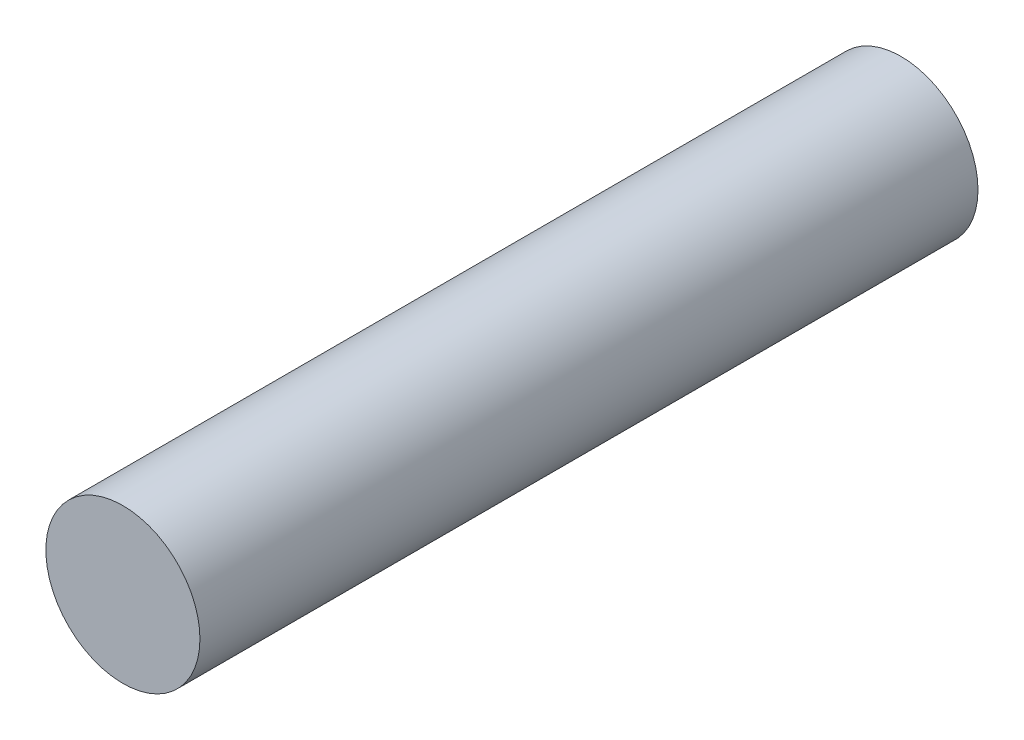
from build123d import *

# Parameters (mm, degrees)
SKETCH1_R           = 2.54
BOSS_EXTRUDE1_DEPTH = 25.65


with BuildPart() as part:
    # Sketch1 → Boss-Extrude1 (new body)
    with BuildSketch(Plane.XY):
        Circle(SKETCH1_R)
    extrude(amount=BOSS_EXTRUDE1_DEPTH)


solid = part.part
